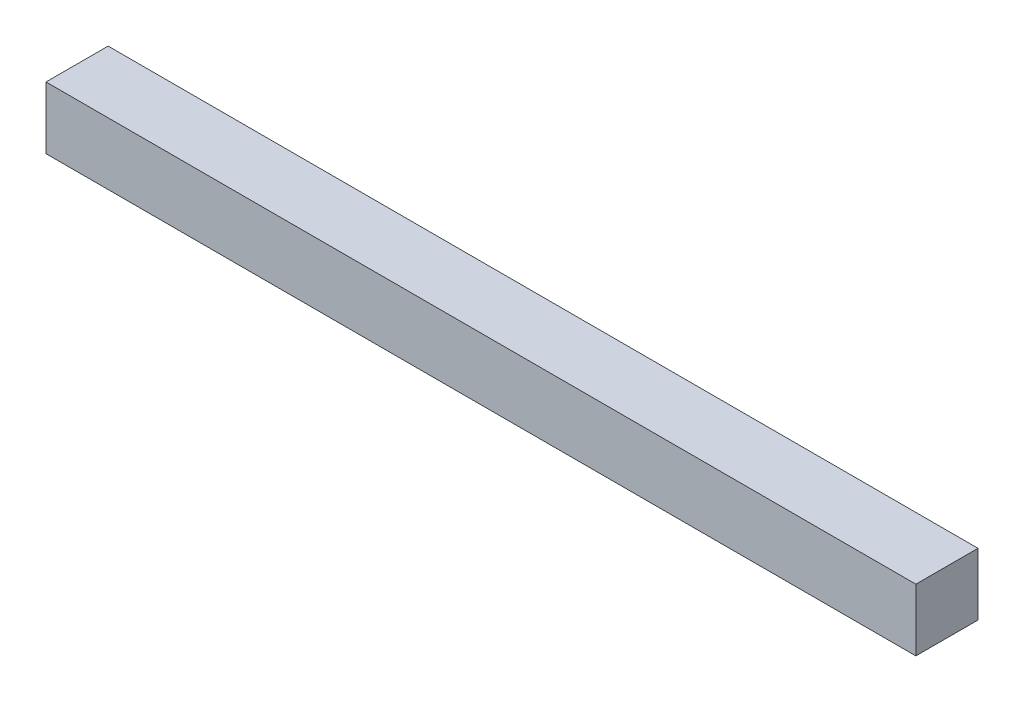
from build123d import *

# Parameters (mm, degrees)
SKETCH1_W           = 70
SKETCH1_H           = 5
BOSS_EXTRUDE1_DEPTH = 5


with BuildPart() as part:
    # Sketch1 → Boss-Extrude1 (new body)
    with BuildSketch(Plane(origin=(0, 0, 0), x_dir=(1, 0, 0), z_dir=(0, 1, 0))):
        with Locations((35, 2.5)):
            Rectangle(SKETCH1_W, SKETCH1_H)
    extrude(amount=BOSS_EXTRUDE1_DEPTH)


solid = part.part
